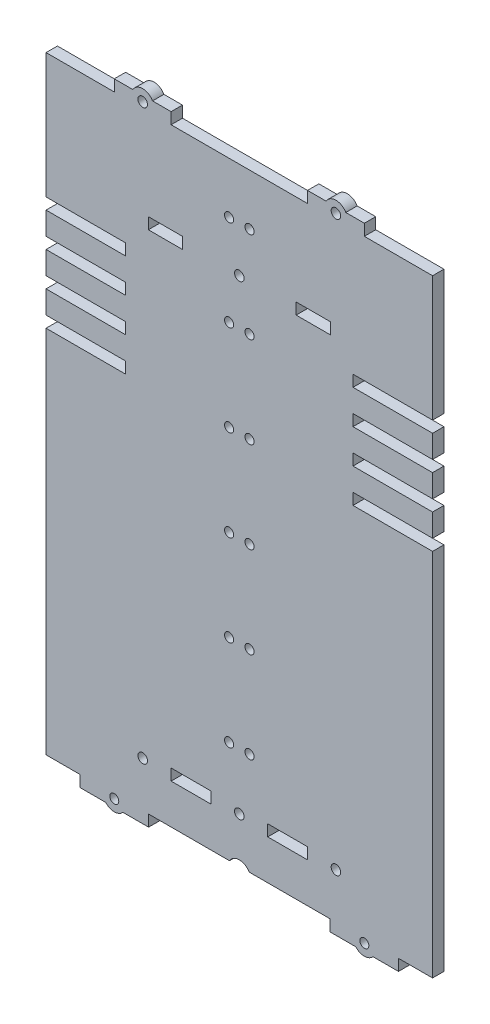
from build123d import *

# Parameters (mm, degrees)
SKETCH1_W           = 15
SKETCH1_H           = 5
BOSS_EXTRUDE1_DEPTH = 5
CUT_EXTRUDE1_DEPTH  = 5
SKETCH3_R           = 2.1
CUT_EXTRUDE2_DEPTH  = 5
BOSS_EXTRUDE2_DEPTH = 5
SKETCH5_R           = 2.1
CUT_EXTRUDE3_DEPTH  = 5
SKETCH7_R           = 2.1
SKETCH7_R_2         = 1.973564221
BOSS_EXTRUDE3_DEPTH = 5
SKETCH8_R           = 2.1
CUT_EXTRUDE5_DEPTH  = 5
BOSS_EXTRUDE4_DEPTH = 5
SKETCH10_R          = 2
CUT_EXTRUDE6_DEPTH  = 10
SKETCH11_W          = 5
SKETCH11_H          = 5
BOSS_EXTRUDE5_DEPTH = 0.1
SKETCH12_W          = 5
SKETCH12_H          = 5
BOSS_EXTRUDE6_DEPTH = 0.1


with BuildPart() as part:
    # Sketch1 → Boss-Extrude1 (new body)
    with BuildSketch(Plane.XY):
        Polygon((-72.5, 0), (0, 0), (0, 140), (-35, 140), (-35, 145), (0, 145), (0, 155), (-35, 155), (-35, 160), (0, 160), (0, 170), (-35, 170), (-35, 175), (0, 175), (0, 185), (-35, 185), (-35, 190), (0, 190), (0, 245), (-30, 245), (-30, 250), (-55, 250), (-55, 245), (-115, 245), (-115, 250), (-140, 250), (-140, 245), (-170, 245), (-170, 190), (-135, 190), (-135, 185), (-170, 185), (-170, 175), (-135, 175), (-135, 170), (-170, 170), (-170, 160), (-135, 160), (-135, 155), (-170, 155), (-170, 145), (-135, 145), (-135, 140), (-170, 140), (-170, 0), (-97.5, 0), (-97.5, -5), (-72.5, -5), align=None)
        with Locations((-117.5, 202.5)):
            Rectangle(SKETCH1_W, SKETCH1_H, mode=Mode.SUBTRACT)
        with Locations((-52.5, 202.5)):
            Rectangle(SKETCH1_W, SKETCH1_H, mode=Mode.SUBTRACT)
    extrude(amount=BOSS_EXTRUDE1_DEPTH)

    # Sketch2 → Cut-Extrude1 (cut)
    with BuildSketch(Plane.XY.offset(5)):
        with BuildLine():
            Line((-123.169872981, 0), (-131.830127019, 0))
            ThreePointArc((-131.830127019, 0), (-127.5, 2.5), (-123.169872981, 0))
        make_face()
        with BuildLine():
            Line((-46.830127019, 0), (-38.169872981, 0))
            ThreePointArc((-38.169872981, 0), (-42.5, 2.5), (-46.830127019, 0))
        make_face()
    extrude(amount=-CUT_EXTRUDE1_DEPTH, mode=Mode.SUBTRACT)

    # Sketch3 → Cut-Extrude2 (cut)
    with BuildSketch(Plane.XY.offset(5)):
        with Locations((-85, -2.5)):
            Circle(SKETCH3_R)
    extrude(amount=-CUT_EXTRUDE2_DEPTH, mode=Mode.SUBTRACT)

    # Sketch4 → Boss-Extrude2 (add)
    with BuildSketch(Plane.XY.offset(5)):
        with BuildLine():
            Line((-89.330127019, -5), (-80.669872981, -5))
            ThreePointArc((-80.669872981, -5), (-85, -7.5), (-89.330127019, -5))
        make_face()
    extrude(amount=-BOSS_EXTRUDE2_DEPTH)

    # Sketch5 → Cut-Extrude3 (cut)
    with BuildSketch(Plane.XY.offset(5)):
        with Locations((-85, 202.5)):
            Circle(SKETCH5_R)
    extrude(amount=-CUT_EXTRUDE3_DEPTH, mode=Mode.SUBTRACT)

    # Sketch7 → Boss-Extrude3 (add)
    with BuildSketch(Plane.XY.offset(5)):
        with BuildLine():
            Line((-55, 0), (-55, -5))
            Line((-55, -5), (-80.669872981, -5))
            ThreePointArc((-80.669872981, -5), (-85, -7.5), (-89.330127019, -5))
            Line((-89.330127019, -5), (-115, -5))
            Line((-115, -5), (-115, 0))
            Line((-115, 0), (-123.169872981, 0))
            ThreePointArc((-123.169872981, 0), (-127.5, 2.5), (-131.830127019, 0))
            Line((-131.830127019, 0), (-170, 0))
            Line((-170, 0), (-170, -22.5))
            Line((-170, -22.5), (-155, -22.5))
            Line((-155, -22.5), (-155, -27.5))
            Line((-155, -27.5), (-143.770676698, -27.5))
            ThreePointArc((-143.770676698, -27.5), (-140, -29.21640483), (-136.229323302, -27.5))
            Line((-136.229323302, -27.5), (-125, -27.5))
            Line((-125, -27.5), (-125, -22.5))
            Line((-125, -22.5), (-89.330127019, -22.5))
            ThreePointArc((-89.330127019, -22.5), (-85, -20), (-80.669872981, -22.5))
            Line((-80.669872981, -22.5), (-45, -22.5))
            Line((-45, -22.5), (-45, -27.5))
            Line((-45, -27.5), (-33.770676698, -27.5))
            ThreePointArc((-33.770676698, -27.5), (-30, -29.21640483), (-26.229323302, -27.5))
            Line((-26.229323302, -27.5), (-15, -27.5))
            Line((-15, -27.5), (-15, -22.5))
            Line((-15, -22.5), (0, -22.5))
            Line((0, -22.5), (0, 0))
            Line((0, 0), (-38.169872981, 0))
            ThreePointArc((-38.169872981, 0), (-42.5, 2.5), (-46.830127019, 0))
            Line((-46.830127019, 0), (-55, 0))
        make_face()
        with Locations((-42.5, -2.5)):
            Circle(SKETCH7_R, mode=Mode.SUBTRACT)
        with Locations((-30, -24.21640483)):
            Circle(SKETCH7_R_2, mode=Mode.SUBTRACT)
        with Locations((-140, -24.21640483)):
            Circle(SKETCH7_R_2, mode=Mode.SUBTRACT)
        with Locations((-127.5, -2.5)):
            Circle(SKETCH7_R, mode=Mode.SUBTRACT)
    extrude(amount=-BOSS_EXTRUDE3_DEPTH)

    # Sketch8 → Cut-Extrude5 (cut)
    with BuildSketch(Plane.XY.offset(5)):
        with Locations((-42.5, 247.5)):
            Circle(SKETCH8_R)
        with Locations((-127.5, 247.5)):
            Circle(SKETCH8_R)
    extrude(amount=-CUT_EXTRUDE5_DEPTH, mode=Mode.SUBTRACT)

    # Sketch9 → Boss-Extrude4 (add)
    with BuildSketch(Plane.XY.offset(5)):
        with BuildLine():
            Line((-46.830127019, 250), (-38.169872981, 250))
            ThreePointArc((-38.169872981, 250), (-42.5, 252.5), (-46.830127019, 250))
        make_face()
        with BuildLine():
            Line((-123.169872981, 250), (-131.830127019, 250))
            ThreePointArc((-131.830127019, 250), (-127.5, 252.5), (-123.169872981, 250))
        make_face()
    extrude(amount=-BOSS_EXTRUDE4_DEPTH)

    # Sketch10 → Cut-Extrude6 (cut)
    with BuildSketch(Plane.XY.offset(5)):
        with Locations((-80.5, 22.5)):
            Circle(SKETCH10_R)
        with Locations((-80.5, 62.5)):
            Circle(SKETCH10_R)
        with Locations((-80.5, 102.5)):
            Circle(SKETCH10_R)
        with Locations((-80.5, 142.5)):
            Circle(SKETCH10_R)
        with Locations((-80.5, 182.5)):
            Circle(SKETCH10_R)
        with Locations((-80.5, 222.5)):
            Circle(SKETCH10_R)
        with Locations((-89.5, 222.5)):
            Circle(SKETCH10_R)
        with Locations((-89.5, 182.5)):
            Circle(SKETCH10_R)
        with Locations((-89.5, 142.5)):
            Circle(SKETCH10_R)
        with Locations((-89.5, 102.5)):
            Circle(SKETCH10_R)
        with Locations((-89.5, 62.5)):
            Circle(SKETCH10_R)
        with Locations((-89.5, 22.5)):
            Circle(SKETCH10_R)
    extrude(amount=-CUT_EXTRUDE6_DEPTH, mode=Mode.SUBTRACT)

    # Sketch11 → Boss-Extrude5 (add)
    with BuildSketch(Plane.ZY.offset(45)):
        with Locations((2.5, -25)):
            Rectangle(SKETCH11_W, SKETCH11_H)
    extrude(amount=BOSS_EXTRUDE5_DEPTH)

    # Sketch12 → Boss-Extrude6 (add)
    with BuildSketch(Plane(origin=(-125, 0, 0), x_dir=(0, 0, -1), z_dir=(1, 0, 0))):
        with Locations((-2.5, -25)):
            Rectangle(SKETCH12_W, SKETCH12_H)
    extrude(amount=BOSS_EXTRUDE6_DEPTH)


solid = part.part
